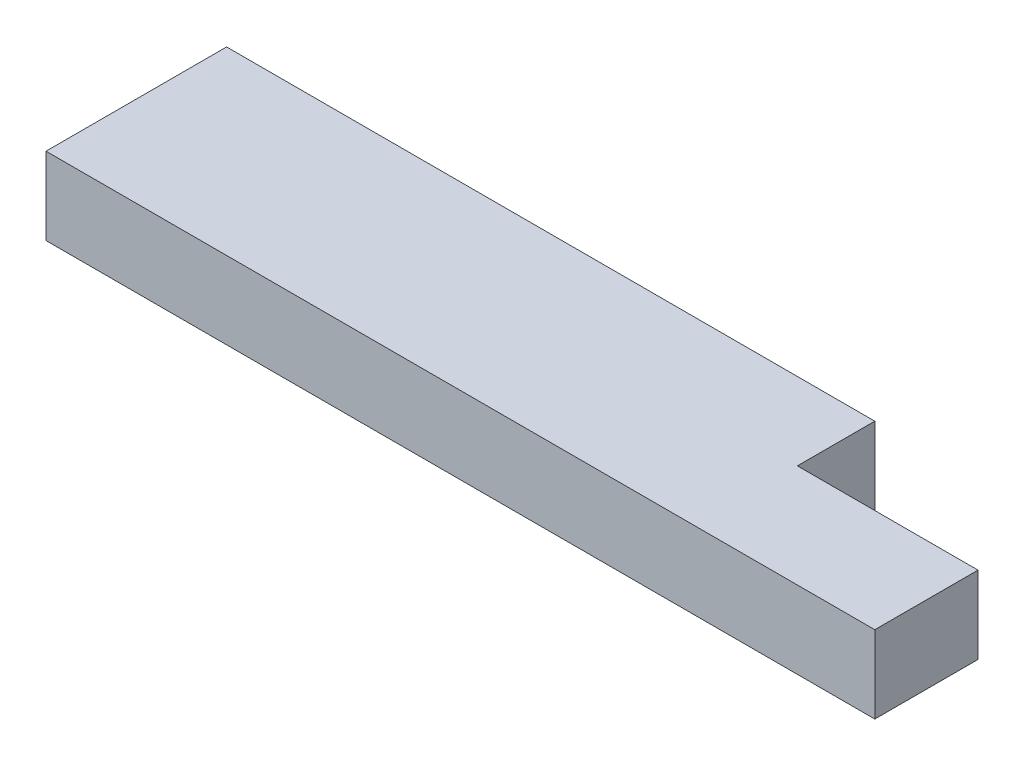
from build123d import *

# Parameters (mm, degrees)
SKETCH1_W           = 319.0875
SKETCH1_H           = 88.9
BOSS_EXTRUDE1_DEPTH = 38.1
SKETCH2_W           = 88.9
SKETCH2_H           = 50.8
BOSS_EXTRUDE2_DEPTH = 38.1


with BuildPart() as part:
    # Sketch1 → Boss-Extrude1 (new body)
    with BuildSketch(Plane(origin=(0, 0, 0), x_dir=(1, 0, 0), z_dir=(0, 1, 0))):
        with Locations((159.54375, 44.45)):
            Rectangle(SKETCH1_W, SKETCH1_H)
    extrude(amount=BOSS_EXTRUDE1_DEPTH)

    # Sketch2 → Boss-Extrude2 (add, through all)
    with BuildSketch(Plane.XZ):
        with Locations((363.5375, -25.4)):
            Rectangle(SKETCH2_W, SKETCH2_H)
    extrude(amount=-BOSS_EXTRUDE2_DEPTH)


solid = part.part
